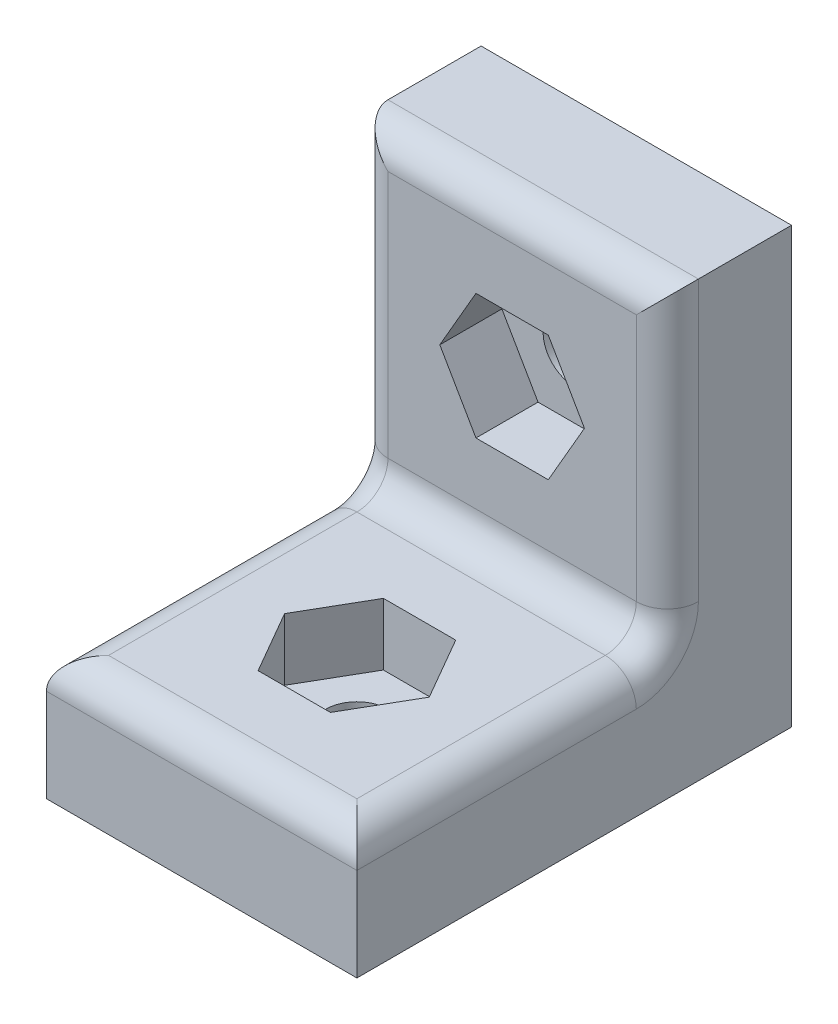
from build123d import *

# Parameters (mm, degrees)
ESQUISSE1_W             = 10
ESQUISSE1_H             = 14
BOSS_EXTRU_1_DEPTH      = 4
ESQUISSE2_W             = 10
ESQUISSE2_H             = 4
BOSS_EXTRU_2_DEPTH      = 10
ESQUISSE3_R             = 1
ENL_V_MAT_EXTRU_1_DEPTH = 5
CONG_1_R                = 1
ESQUISSE4_R             = 1
ENL_V_MAT_EXTRU_2_DEPTH = 5
ENL_V_MAT_EXTRU_3_DEPTH = 2
ENL_V_MAT_EXTRU_4_DEPTH = 2


with BuildPart() as part:
    # Esquisse1 → Boss.-Extru.1 (new body)
    with BuildSketch(Plane.XY):
        with Locations((0, 7)):
            Rectangle(ESQUISSE1_W, ESQUISSE1_H)
    extrude(amount=BOSS_EXTRU_1_DEPTH)

    # Esquisse2 → Boss.-Extru.2 (add)
    with BuildSketch(Plane.XY.offset(4)):
        with Locations((0, 2)):
            Rectangle(ESQUISSE2_W, ESQUISSE2_H)
    extrude(amount=BOSS_EXTRU_2_DEPTH)

    # Esquisse3 → Enlèv. mat.-Extru.1 (cut, through all)
    with BuildSketch(Plane.XY.offset(4)):
        with Locations((0, 9)):
            Circle(ESQUISSE3_R)
    extrude(amount=-ENL_V_MAT_EXTRU_1_DEPTH, mode=Mode.SUBTRACT)

    # Congé1
    cong_1_edges = [part.edges().sort_by_distance(p)[0] for p in [
        (5, 9, 4),
        (-5, 4, 9),
        (0, 4, 4),
        (5, 4, 9),
        (0, 14, 4),
        (0, 4, 14),
        (-5, 9, 4),
    ]]
    fillet(cong_1_edges, radius=CONG_1_R)

    # Esquisse4 → Enlèv. mat.-Extru.2 (cut, through all)
    with BuildSketch(Plane(origin=(0, 4, 0), x_dir=(1, 0, 0), z_dir=(0, 1, 0))):
        with Locations(Location((0, -9, 0), (0, 0, 270))):  # turned: the seam where the file's is
            Circle(ESQUISSE4_R)
    extrude(amount=-ENL_V_MAT_EXTRU_2_DEPTH, mode=Mode.SUBTRACT)

    # Esquisse5 → Enlèv. mat.-Extru.3 (cut)
    with BuildSketch(Plane.XY.offset(4)):
        Polygon((1.165, 6.982160809), (2.33, 9), (1.165, 11.017839191), (-1.165, 11.017839191), (-2.33, 9), (-1.165, 6.982160809), align=None)
    extrude(amount=-ENL_V_MAT_EXTRU_3_DEPTH, mode=Mode.SUBTRACT)

    # Esquisse6 → Enlèv. mat.-Extru.4 (cut)
    with BuildSketch(Plane(origin=(0, 4, 0), x_dir=(1, 0, 0), z_dir=(0, 1, 0))):
        Polygon((2.33, -9), (1.165, -6.982160809), (-1.165, -6.982160809), (-2.33, -9), (-1.165, -11.017839191), (1.165, -11.017839191), align=None)
    extrude(amount=-ENL_V_MAT_EXTRU_4_DEPTH, mode=Mode.SUBTRACT)


solid = part.part
